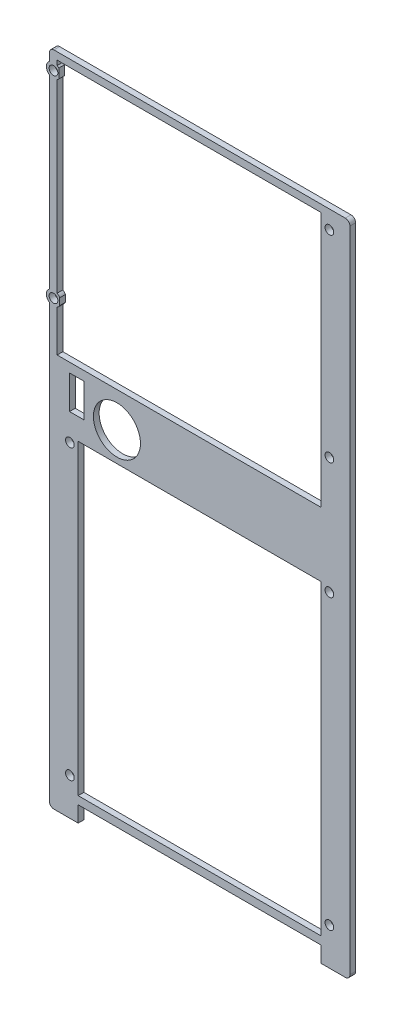
from build123d import *

# Parameters (mm, degrees)
SKETCH1_R          = 13.062040361
SKETCH1_R_2        = 2.413
SKETCH1_W          = 134.896048872
SKETCH1_H          = 170.361865006
SKETCH1_W_2        = 8.101943593
SKETCH1_H_2        = 18.586811772
BASE_EXTRUDE_DEPTH = 3.175


with BuildPart() as part:
    # Sketch1 → Base-Extrude (new body)
    with BuildSketch(Plane.XY):
        with BuildLine():
            Line((67.448024436, -180.870824712), (80.875311853, -180.870824712))
            ThreePointArc((80.875311853, -180.870824712), (82.671363078, -180.126875936), (83.415311853, -178.330824712))
            Line((83.415311853, -178.330824712), (83.415311853, 181.634401419))
            ThreePointArc((83.415311853, 181.634401419), (82.671363078, 183.430452643), (80.875311853, 184.174401419))
            Line((80.875311853, 184.174401419), (67.448024436, 184.174401419))
            Line((67.448024436, 184.174401419), (-80.875311853, 184.174401419))
            ThreePointArc((-80.875311853, 184.174401419), (-82.671363078, 183.430452643), (-83.415311853, 181.634401419))
            Line((-83.415311853, 181.634401419), (-83.415311853, 177.378670652))
            ThreePointArc((-83.415311853, 177.378670652), (-85.086906608, 174.158747039), (-83.415311853, 170.938823426))
            Line((-83.415311853, 170.938823426), (-83.415311853, 67.926183644))
            ThreePointArc((-83.415311853, 67.926183644), (-85.086906608, 64.706260031), (-83.415311853, 61.486336418))
            Line((-83.415311853, 61.486336418), (-83.415311853, -178.330824712))
            ThreePointArc((-83.415311853, -178.330824712), (-82.671363078, -180.126875936), (-80.875311853, -180.870824712))
            Line((-80.875311853, -180.870824712), (-67.448024436, -180.870824712))
            Line((-67.448024436, -180.870824712), (-67.448024436, -172.061286826))
            Line((-67.448024436, -172.061286826), (67.448024436, -172.061286826))
            Line((67.448024436, -172.061286826), (67.448024436, -180.870824712))
        make_face()
        with Locations((-45.925033829, 18.948035519)):
            Circle(SKETCH1_R, mode=Mode.SUBTRACT)
        with Locations((-81.149906608, 174.158747039)):
            Circle(SKETCH1_R_2, mode=Mode.SUBTRACT)
        with Locations((-72.033370308, -0.104595883)):
            Circle(SKETCH1_R_2, mode=Mode.SUBTRACT)
        with Locations((-72.033370308, -160.140032971)):
            Circle(SKETCH1_R_2, mode=Mode.SUBTRACT)
        with Locations((72.033370308, -160.140032971)):
            Circle(SKETCH1_R_2, mode=Mode.SUBTRACT)
        with Locations((72.033370308, 174.158747039)):
            Circle(SKETCH1_R_2, mode=Mode.SUBTRACT)
        with Locations((72.033370308, 64.706260031)):
            Circle(SKETCH1_R_2, mode=Mode.SUBTRACT)
        with Locations((72.033370308, -0.104595883)):
            Circle(SKETCH1_R_2, mode=Mode.SUBTRACT)
        with Locations((-81.149906608, 64.706260031)):
            Circle(SKETCH1_R_2, mode=Mode.SUBTRACT)
        with BuildLine():
            Line((67.448024436, 180.158408435), (67.448024436, 38.374253759))
            Line((67.448024436, 38.374253759), (-79.118458404, 38.374253759))
            Line((-79.118458404, 38.374253759), (-79.118458404, 61.333844399))
            ThreePointArc((-79.118458404, 61.333844399), (-78.309050002, 61.980548611), (-77.696370086, 62.816007537))
            Line((-77.696370086, 62.816007537), (-77.696370086, 66.596512525))
            ThreePointArc((-77.696370086, 66.596512525), (-78.309050002, 67.431971452), (-79.118458404, 68.078675663))
            Line((-79.118458404, 68.078675663), (-79.118458404, 170.786331407))
            ThreePointArc((-79.118458404, 170.786331407), (-78.634491656, 171.130107638), (-78.207715157, 171.542742745))
            Line((-78.207715157, 171.542742745), (-78.207715157, 176.774751333))
            ThreePointArc((-78.207715157, 176.774751333), (-78.634491656, 177.18738644), (-79.118458404, 177.531162671))
            Line((-79.118458404, 177.531162671), (-79.118458404, 180.158408435))
            Line((-79.118458404, 180.158408435), (67.448024436, 180.158408435))
        make_face(mode=Mode.SUBTRACT)
        with Locations((0, -82.475585381)):
            Rectangle(SKETCH1_W, SKETCH1_H, mode=Mode.SUBTRACT)
        with Locations((-68.175247928, 23.913375939)):
            Rectangle(SKETCH1_W_2, SKETCH1_H_2, mode=Mode.SUBTRACT)
    extrude(amount=-BASE_EXTRUDE_DEPTH)


solid = part.part
